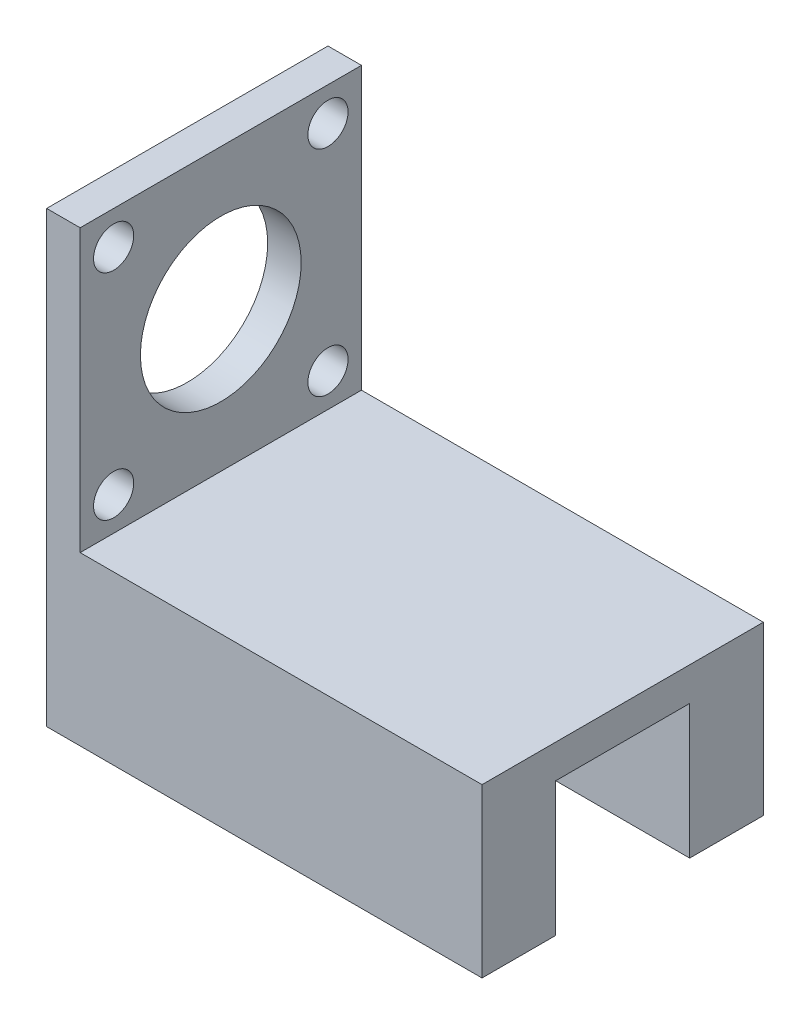
from build123d import *

# Parameters (mm, degrees)
SKETCH_1_W          = 65
SKETCH_1_H          = 11
EXTRUDE_1_DEPTH     = 20
EXTRUDE_1_2_DEPTH   = 20
SKETCH_2_W          = 65
SKETCH_2_H          = 42
EXTRUDE_2_DEPTH     = 5
SKETCH_3_W          = 5
SKETCH_3_H          = 42
EXTRUDE_3_DEPTH     = 42
SKETCH_5_R          = 12
SKETCH_5_R_2        = 3
CUT_EXTRUDE_3_DEPTH = 42


with BuildPart() as part:
    # 草图1 → 凸台-拉伸1 (new body)
    with BuildSketch(Plane(origin=(0, 0, 0), x_dir=(1, 0, 0), z_dir=(0, 1, 0))):
        with Locations((8.014018692, 3.47352182)):
            Rectangle(SKETCH_1_W, SKETCH_1_H)
    extrude(amount=EXTRUDE_1_DEPTH)



with BuildPart() as body_2:
    # 草图1 → Extrude 1 2 (new body)
    with BuildSketch(Plane(origin=(0, 0, 0), x_dir=(1, 0, 0), z_dir=(0, 1, 0))):
        with Locations((8.014018692, -27.52647818)):
            Rectangle(SKETCH_1_W, SKETCH_1_H)
    extrude(amount=EXTRUDE_1_2_DEPTH)


with BuildPart() as part_1:
    add(part.part)

    add(body_2.part)  # 凸台-拉伸2 merges body 2
    # 草图2 → 凸台-拉伸2 (add)
    with BuildSketch(Plane(origin=(0, 20, 0), x_dir=(1, 0, 0), z_dir=(0, 1, 0))):
        with Locations((8.014018692, -12.02647818)):
            Rectangle(SKETCH_2_W, SKETCH_2_H)
    extrude(amount=EXTRUDE_2_DEPTH)

    # 草图3 → 凸台-拉伸3 (add)
    with BuildSketch(Plane(origin=(0, 25, 0), x_dir=(1, 0, 0), z_dir=(0, 1, 0))):
        with Locations((-21.985981308, -12.02647818)):
            Rectangle(SKETCH_3_W, SKETCH_3_H)
    extrude(amount=EXTRUDE_3_DEPTH)

    # 草图5 → 切除-拉伸3 (cut)
    with BuildSketch(Plane(origin=(-19.485981308, 0, 0), x_dir=(0, 0, -1), z_dir=(1, 0, 0))):
        with Locations((-12.02647818, 46)):
            Circle(SKETCH_5_R)
        with Locations((-28.02647818, 62)):
            Circle(SKETCH_5_R_2)
        with Locations((3.97352182, 62)):
            Circle(SKETCH_5_R_2)
        with Locations((3.97352182, 30)):
            Circle(SKETCH_5_R_2)
        with Locations((-28.02647818, 30)):
            Circle(SKETCH_5_R_2)
    extrude(amount=-CUT_EXTRUDE_3_DEPTH, mode=Mode.SUBTRACT)


solid = part_1.part
